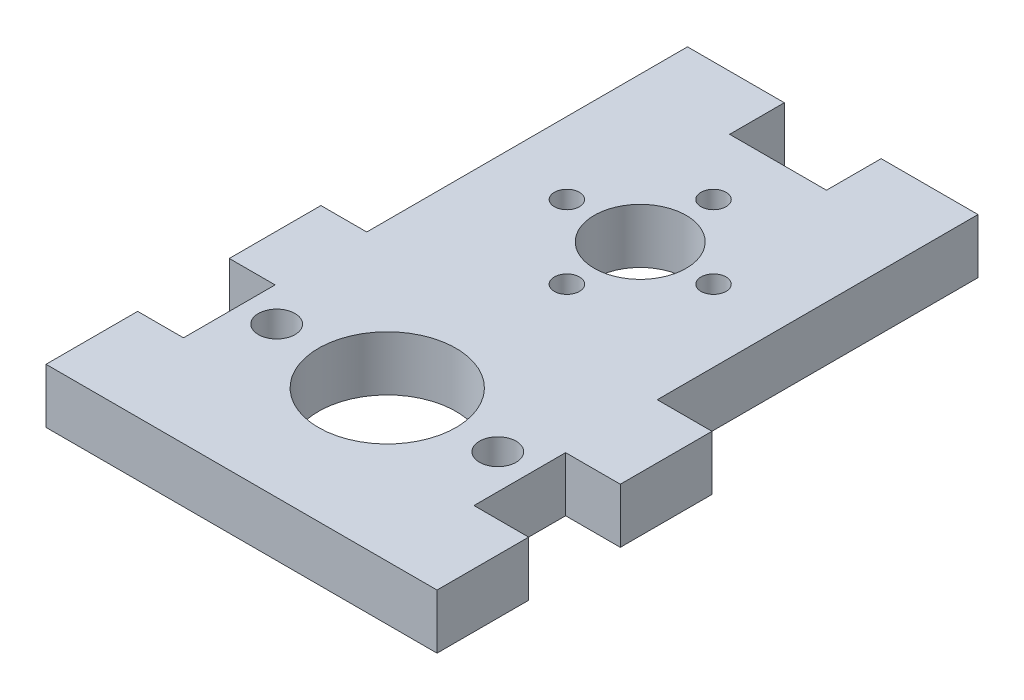
from build123d import *

# Parameters (mm, degrees)
SKETCH1_R           = 5.015
SKETCH1_R_2         = 7.5
BOSS_EXTRUDE1_DEPTH = 5.969
SKETCH2_W           = 5
SKETCH2_H           = 10
SKETCH2_W_2         = 5.969
BOSS_EXTRUDE2_DEPTH = 5.969
SKETCH3_R           = 2
CUT_EXTRUDE1_DEPTH  = 6.969
SKETCH4_R           = 1.37
CUT_EXTRUDE2_DEPTH  = 6.969


with BuildPart() as part:
    # Sketch1 → Boss-Extrude1 (new body)
    with BuildSketch(Plane(origin=(0, 0, 0), x_dir=(1, 0, 0), z_dir=(0, 1, 0))):
        Polygon((0, 0), (31.7, 0), (31.7, 65), (21.133333333, 65), (21.133333333, 59.031), (10.566666667, 59.031), (10.566666667, 65), (0, 65), align=None)
        with Locations((15.85, 43.99)):
            Circle(SKETCH1_R, mode=Mode.SUBTRACT)
        with Locations((15.85, 16.3861)):
            Circle(SKETCH1_R_2, mode=Mode.SUBTRACT)
    extrude(amount=BOSS_EXTRUDE1_DEPTH)

    # Sketch2 → Boss-Extrude2 (add)
    with BuildSketch(Plane(origin=(0, 5.969, 0), x_dir=(1, 0, 0), z_dir=(0, 1, 0))):
        with Locations((-2.5, 5)):
            Rectangle(SKETCH2_W, SKETCH2_H)
        with Locations((-2.5, 25)):
            Rectangle(SKETCH2_W, SKETCH2_H)
        with Locations((34.6845, 25)):
            Rectangle(SKETCH2_W_2, SKETCH2_H)
        with Locations((34.6845, 5)):
            Rectangle(SKETCH2_W_2, SKETCH2_H)
    extrude(amount=-BOSS_EXTRUDE2_DEPTH)

    # Sketch3 → Cut-Extrude1 (cut, through all)
    with BuildSketch(Plane.XZ):
        with Locations((27.915, -16.3861)):
            Circle(SKETCH3_R)
        with Locations((3.785, -16.3861)):
            Circle(SKETCH3_R)
    extrude(amount=-CUT_EXTRUDE1_DEPTH, mode=Mode.SUBTRACT)

    # Sketch4 → Cut-Extrude2 (cut, through all)
    with BuildSketch(Plane.XZ):
        with Locations((23.85, -43.99)):
            Circle(SKETCH4_R)
        with Locations((15.85, -51.99)):
            Circle(SKETCH4_R)
        with Locations((15.85, -35.99)):
            Circle(SKETCH4_R)
        with Locations((7.85, -43.99)):
            Circle(SKETCH4_R)
    extrude(amount=-CUT_EXTRUDE2_DEPTH, mode=Mode.SUBTRACT)


solid = part.part
